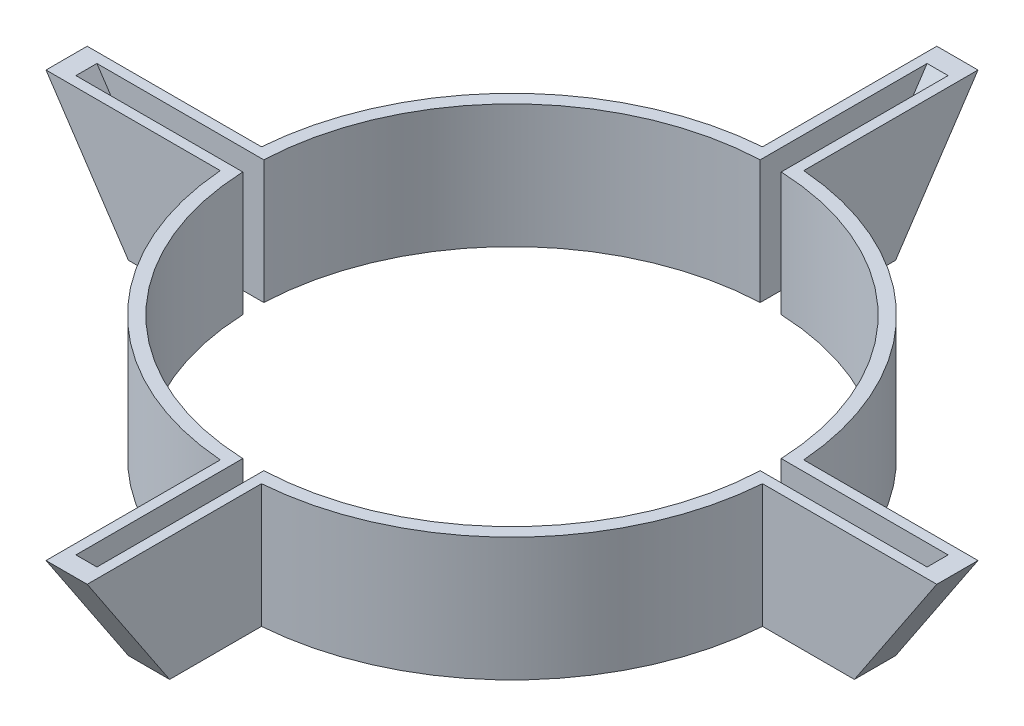
from build123d import *

# Parameters (mm, degrees)
SKETCH1_R                = 41.9034
SKETCH1_R_2              = 39.9034
BOSS_EXTRUDE1_DEPTH      = 57.15
BOSS_EXTRUDE2_REACH      = 137.075
BOSS_EXTRUDE2_END_RADIUS = 41.9034
SKETCH4_W                = 6.35
SKETCH4_H                = 96.707907256
CUT_EXTRUDE1_REACH       = 161.401
CUT_EXTRUDE1_END_RADIUS  = 39.9034
SKETCH5_W                = 3.2385
SKETCH5_H                = 67.115737741
CIRPATTERN1_COUNT        = 4
SKETCH6_W                = 191.094400596
SKETCH6_H                = 76.2
SKETCH6_H_2              = 57.15
CUT_EXTRUDE2_DEPTH       = 154.043134259
CUT_EXTRUDE2_DEPTH_BACK  = 154.043134259


with BuildPart() as part:
    # Sketch1 → Boss-Extrude1 (new, symmetric)
    with BuildSketch(Plane(origin=(0, 0, 0), x_dir=(1, 0, 0), z_dir=(0, 1, 0))):
        with Locations(Location((0, 0, 0), (0, 0, 270))):
            Circle(SKETCH1_R)
        with Locations(Location((0, 0, 0), (0, 0, 270))):
            Circle(SKETCH1_R_2, mode=Mode.SUBTRACT)
    extrude(amount=BOSS_EXTRUDE1_DEPTH, both=True)

    # Boss-Extrude2: up to this cylinder (the profile starts outside it)
    boss_extrude2_end = Plane(origin=(0, -4.217047, 0), z_dir=(0, -1, 0)) * Cylinder(BOSS_EXTRUDE2_END_RADIUS, 358.9568, mode=Mode.PRIVATE)
    # Sketch4 → Boss-Extrude2 (add, up to the surface)
    with BuildSketch(Plane(origin=(0, -33.016886495, -49.525456207), x_dir=(1, 0, 0), z_dir=(0, 0.5546992156114063, 0.8320509480795575)), mode=Mode.PRIVATE) as boss_extrude2_sk1:
        with Locations((0, 34.613072097)):
            Rectangle(SKETCH4_W, SKETCH4_H)
    boss_extrude2_tool1 = extrude(boss_extrude2_sk1.sketch, amount=BOSS_EXTRUDE2_REACH, mode=Mode.PRIVATE) - boss_extrude2_end
    boss_extrude2 = boss_extrude2_tool1.solids().sort_by_distance((0, -4.217047, -68.7253))[0]
    add(boss_extrude2)

    # Cut-Extrude1: up to this cylinder (the profile starts outside it)
    cut_extrude1_end = Plane(origin=(0, 56.039365, 0), z_dir=(0, -1, 0)) * Cylinder(CUT_EXTRUDE1_END_RADIUS, 403.6088, mode=Mode.PRIVATE)
    # Sketch5 → Cut-Extrude1 (cut, up to the surface)
    with BuildSketch(Plane(origin=(0, 69.032792414, -46.021744091), x_dir=(1, 0, 0), z_dir=(0, 0.8320509480795577, -0.5546992156114063)), mode=Mode.PRIVATE) as cut_extrude1_sk1:
        with Locations((0, 23.424274962)):
            Rectangle(SKETCH5_W, SKETCH5_H)
    cut_extrude1_tool1 = extrude(cut_extrude1_sk1.sketch, amount=-CUT_EXTRUDE1_REACH, mode=Mode.PRIVATE) - cut_extrude1_end
    cut_extrude1 = cut_extrude1_tool1.solids().sort_by_distance((0, 56.039365, -65.511934))[0]
    add(cut_extrude1, mode=Mode.SUBTRACT)

    # CirPattern1: Boss-Extrude2, Cut-Extrude1 ×4 about axis
    cirpattern1_axis = Axis((0, 0, 0), (0, 1, 0))
    add([boss_extrude2.rotate(cirpattern1_axis, i * 360 / CIRPATTERN1_COUNT) for i in range(1, CIRPATTERN1_COUNT)])
    add([cut_extrude1.rotate(cirpattern1_axis, i * 360 / CIRPATTERN1_COUNT) for i in range(1, CIRPATTERN1_COUNT)], mode=Mode.SUBTRACT)

    # Sketch6 → Cut-Extrude2 (cut, two sides)
    with BuildSketch(Plane(origin=(0, 0, 0), x_dir=(0, 0, -1), z_dir=(1, 0, 0))) as cut_extrude2_sk:
        with Locations((0, 33.758652745)):
            Rectangle(SKETCH6_W, SKETCH6_H)
        with Locations((0, -51.966347255)):
            Rectangle(SKETCH6_W, SKETCH6_H_2)
    extrude(amount=CUT_EXTRUDE2_DEPTH, mode=Mode.SUBTRACT)
    extrude(cut_extrude2_sk.sketch, amount=-CUT_EXTRUDE2_DEPTH_BACK, mode=Mode.SUBTRACT)


solid = part.part
